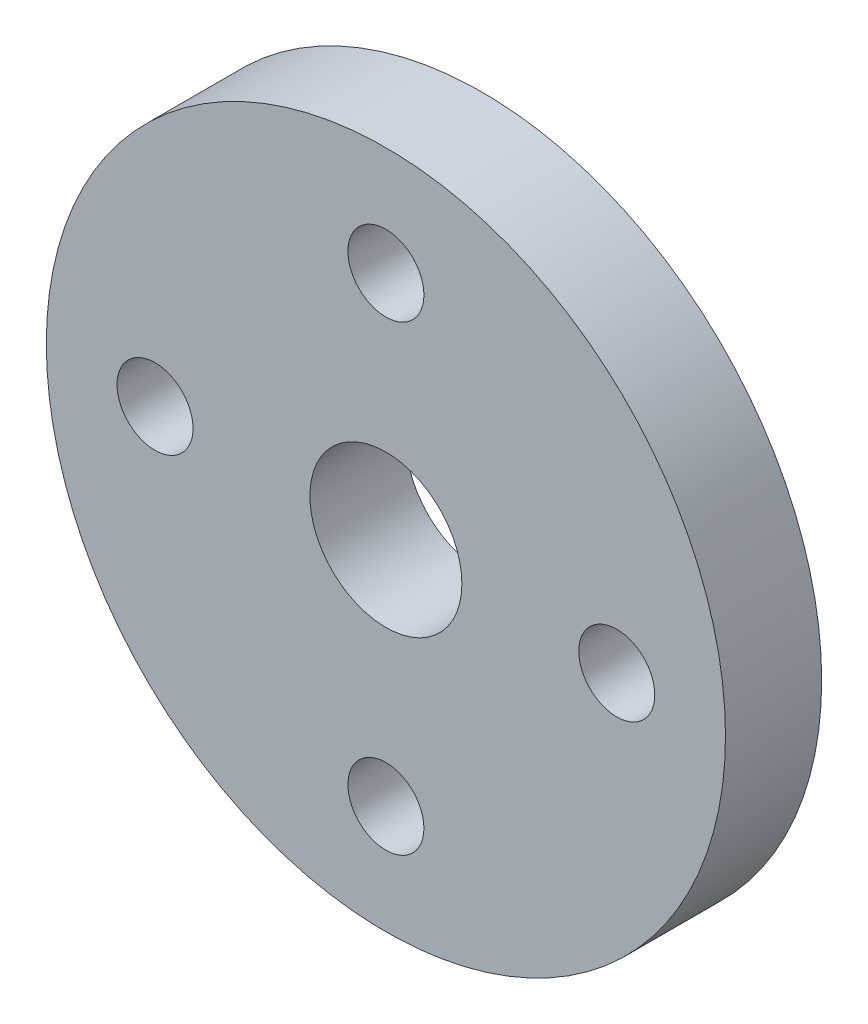
from build123d import *

# Parameters (mm, degrees)
SKETCH1_R           = 17.65
SKETCH1_R_2         = 3.95
SKETCH1_R_3         = 1.975
BOSS_EXTRUDE1_DEPTH = 5


with BuildPart() as part:
    # Sketch1 → Boss-Extrude1 (new body)
    with BuildSketch(Plane.XY):
        Circle(SKETCH1_R)
        Circle(SKETCH1_R_2, mode=Mode.SUBTRACT)
        with Locations((0, 12)):
            Circle(SKETCH1_R_3, mode=Mode.SUBTRACT)
        with Locations((12, 0)):
            Circle(SKETCH1_R_3, mode=Mode.SUBTRACT)
        with Locations((0, -12)):
            Circle(SKETCH1_R_3, mode=Mode.SUBTRACT)
        with Locations((-12, 0)):
            Circle(SKETCH1_R_3, mode=Mode.SUBTRACT)
    extrude(amount=BOSS_EXTRUDE1_DEPTH)


solid = part.part
